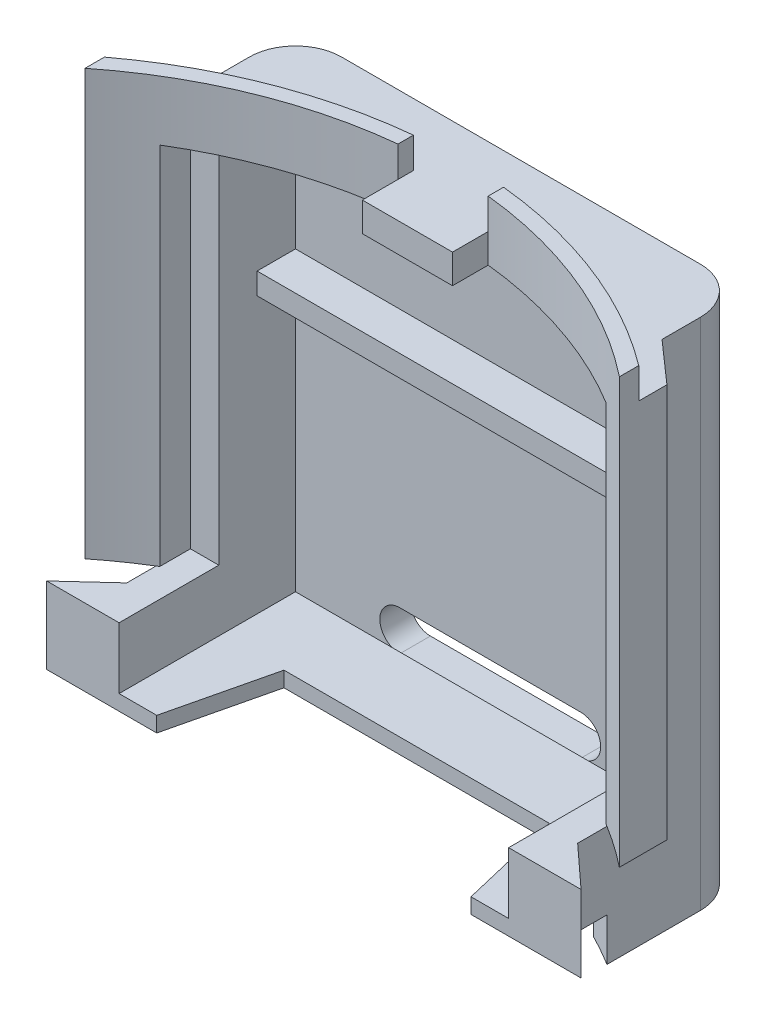
from build123d import *

# Parameters (mm, degrees)
EXTRUDE_1_DEPTH     = 17.75
CUT_EXTRUDE_1_DEPTH = 1
SKETCH_3_W          = 2.94
SKETCH_3_H          = 1
CUT_EXTRUDE_2_DEPTH = 6.5
CUT_EXTRUDE_3_DEPTH = 3.9
SKETCH_5_W          = 12.7
SKETCH_5_H          = 2.983573368
CUT_EXTRUDE_4_DEPTH = 1.4
SKETCH_6_W          = 12.7
SKETCH_6_H          = 2.983573368
CUT_EXTRUDE_5_DEPTH = 13.9
SKETCH_7_W          = 14.55
SKETCH_7_H          = 11.9
CUT_EXTRUDE_6_DEPTH = 3
EXTRUDE_2_DEPTH     = 0.5
EXTRUDE_3_DEPTH     = 0.5
EXTRUDE_4_DEPTH     = 2
CUT_EXTRUDE_7_DEPTH = 1
SKETCH_12_W         = 12.7
SKETCH_12_H         = 0.7
EXTRUDE_5_DEPTH     = 1.25
FILLET_1_R          = 1.5
EXTRUDE_6_DEPTH     = 0.95


with BuildPart() as part:
    # Эскиз1 → Бобышка-Вытянуть1 (new body)
    with BuildSketch(Plane(origin=(0, 0, 0), x_dir=(1, 0, 0), z_dir=(0, 1, 0))):
        with BuildLine():
            Line((-7.35, 2.75), (-7.35, 5.5))
            Line((-7.35, 5.5), (7.35, 5.5))
            Line((7.35, 5.5), (7.35, 2.75))
            Line((7.35, 2.75), (8.71, 1.55))
            Line((8.71, 1.55), (8.71, 0))
            ThreePointArc((8.71, 0), (0, 3.039347647), (-8.71, 0))
            Line((-8.71, 0), (-8.71, 1.55))
            Line((-8.71, 1.55), (-7.35, 2.75))
        make_face()
    extrude(amount=EXTRUDE_1_DEPTH)

    # Эскиз2 → Вырез-Вытянуть1 (cut)
    with BuildSketch(Plane(origin=(0, 17.75, 0), x_dir=(1, 0, 0), z_dir=(0, 1, 0))):
        with BuildLine():
            Line((8.71, 0.631840908), (8.71, 1.55))
            Line((8.71, 1.55), (7.35, 2.75))
            Line((7.35, 2.75), (7.35, 5.5))
            Line((7.35, 5.5), (-7.35, 5.5))
            Line((-7.35, 5.5), (-7.35, 2.75))
            Line((-7.35, 2.75), (-8.71, 1.55))
            Line((-8.71, 1.55), (-8.71, 0.631840908))
            ThreePointArc((-8.71, 0.631840908), (0, 3.539347647), (8.71, 0.631840908))
        make_face()
    extrude(amount=-CUT_EXTRUDE_1_DEPTH, mode=Mode.SUBTRACT)

    # Эскиз3 → Вырез-Вытянуть2 (cut, through all)
    with BuildSketch(Plane(origin=(0, 0, -5.5), x_dir=(-1, 0, 0), z_dir=(0, 0, -1))):
        with Locations((0, 17.25)):
            Rectangle(SKETCH_3_W, SKETCH_3_H)
    extrude(amount=-CUT_EXTRUDE_2_DEPTH, mode=Mode.SUBTRACT)

    # Эскиз4 → Вырез-Вытянуть3 (cut)
    with BuildSketch(Plane.XZ):
        with BuildLine():
            Line((-7.35, -2.75), (-7.35, -0.954778819))
            ThreePointArc((-7.35, -0.954778819), (-8.044178059, -0.497584831), (-8.71, 0))
            Line((-8.71, 0), (-8.71, -1.55))
            Line((-8.71, -1.55), (-7.35, -2.75))
        make_face()
        with BuildLine():
            Line((7.35, -2.75), (7.35, -0.954778819))
            ThreePointArc((7.35, -0.954778819), (8.044178059, -0.497584831), (8.71, 0))
            Line((8.71, 0), (8.71, -1.55))
            Line((8.71, -1.55), (7.35, -2.75))
        make_face()
    extrude(amount=-CUT_EXTRUDE_3_DEPTH, mode=Mode.SUBTRACT)

    # Эскиз5 → Вырез-Вытянуть4 (cut)
    with BuildSketch(Plane.XZ):
        with Locations((0, -3.008213316)):
            Rectangle(SKETCH_5_W, SKETCH_5_H)
    extrude(amount=-CUT_EXTRUDE_4_DEPTH, mode=Mode.SUBTRACT)

    # Эскиз6 → Вырез-Вытянуть5 (cut)
    with BuildSketch(Plane(origin=(0, 1.9, 0), x_dir=(-1, 0, 0), z_dir=(0, -1, 0))):
        with Locations((0, 3.008213316)):
            Rectangle(SKETCH_6_W, SKETCH_6_H)
    extrude(amount=-CUT_EXTRUDE_5_DEPTH, mode=Mode.SUBTRACT)

    # Эскиз7 → Вырез-Вытянуть6 (cut, through all)
    with BuildSketch(Plane(origin=(0, 0, -2), x_dir=(-1, 0, 0), z_dir=(0, 0, -1))):
        with Locations((0, 9.85)):
            Rectangle(SKETCH_7_W, SKETCH_7_H)
    extrude(amount=-CUT_EXTRUDE_6_DEPTH, mode=Mode.SUBTRACT)

    # Эскиз8 → Бобышка-Вытянуть2 (add)
    with BuildSketch(Plane.XZ.offset(-1.4)):
        with BuildLine():
            Line((-7.35, 0), (-4.825, 0))
            Line((-4.825, 0), (-4.325, -2.1))
            Line((-4.325, -2.1), (4.325, -2.1))
            Line((4.325, -2.1), (4.825, 0))
            Line((4.825, 0), (7.35, 0))
            Line((7.35, 0), (7.35, -0.954778819))
            ThreePointArc((7.35, -0.954778819), (0, -3.039347647), (-7.35, -0.954778819))
            Line((-7.35, -0.954778819), (-7.35, 0))
        make_face()
    extrude(amount=-EXTRUDE_2_DEPTH)

    # Эскиз9 → Бобышка-Вытянуть3 (add)
    with BuildSketch(Plane.XZ.offset(-1.4)):
        Polygon((-4.825, 0), (-5.122619048, 1.25), (-8.71, 1.25), (-7.35, 0), align=None)
        Polygon((4.825, 0), (5.122619048, 1.25), (8.71, 1.25), (7.35, 0), align=None)
    extrude(amount=-EXTRUDE_3_DEPTH)

    # Эскиз10 → Бобышка-Вытянуть4 (add)
    with BuildSketch(Plane(origin=(0, 1.9, 0), x_dir=(1, 0, 0), z_dir=(0, 1, 0))):
        with BuildLine():
            Line((-7.35, 0), (-8.71, -1.25))
            Line((-8.71, -1.25), (-6.35, -1.25))
            Line((-6.35, -1.25), (-6.35, 1.516426632))
            ThreePointArc((-6.35, 1.516426632), (-6.855753939, 1.24584747), (-7.35, 0.954778819))
            Line((-7.35, 0.954778819), (-7.35, 0))
        make_face()
        with BuildLine():
            Line((7.35, 0), (7.35, 0.954778819))
            ThreePointArc((7.35, 0.954778819), (6.855753939, 1.24584747), (6.35, 1.516426632))
            Line((6.35, 1.516426632), (6.35, -1.25))
            Line((6.35, -1.25), (8.71, -1.25))
            Line((8.71, -1.25), (7.35, 0))
        make_face()
    extrude(amount=EXTRUDE_4_DEPTH)

    # Эскиз11 → Вырез-Вытянуть7 (cut)
    with BuildSketch(Plane(origin=(0, 0, -5.5), x_dir=(-1, 0, 0), z_dir=(0, 0, -1))):
        with BuildLine():
            Line((-2.95, 3.15), (2.95, 3.15))
            ThreePointArc((2.95, 3.15), (3.6, 2.5), (2.95, 1.85))
            Line((2.95, 1.85), (-2.95, 1.85))
            ThreePointArc((-2.95, 1.85), (-3.6, 2.5), (-2.95, 3.15))
        make_face()
    extrude(amount=-CUT_EXTRUDE_7_DEPTH, mode=Mode.SUBTRACT)

    # Эскиз12 → Бобышка-Вытянуть5 (add)
    with BuildSketch(Plane.XY.offset(-4.5)):
        with Locations((0, 11.23)):
            Rectangle(SKETCH_12_W, SKETCH_12_H)
    extrude(amount=EXTRUDE_5_DEPTH)

    # Скругление1
    fillet_1_edges = [part.edges().sort_by_distance(p)[0] for p in [
        (-7.35, 8.375, -5.5),
        (7.35, 8.375, -5.5),
    ]]
    fillet(fillet_1_edges, radius=FILLET_1_R)

    # Эскиз13 → Бобышка-Вытянуть6 (add)
    with BuildSketch(Plane(origin=(0, 16.75, 0), x_dir=(1, 0, 0), z_dir=(0, 1, 0))):
        with BuildLine():
            Line((-1.47, 2.961958753), (-1.47, 1.8))
            Line((-1.47, 1.8), (1.47, 1.8))
            Line((1.47, 1.8), (1.47, 2.961958753))
            ThreePointArc((1.47, 2.961958753), (0, 3.039347647), (-1.47, 2.961958753))
        make_face()
    extrude(amount=-EXTRUDE_6_DEPTH)


solid = part.part
